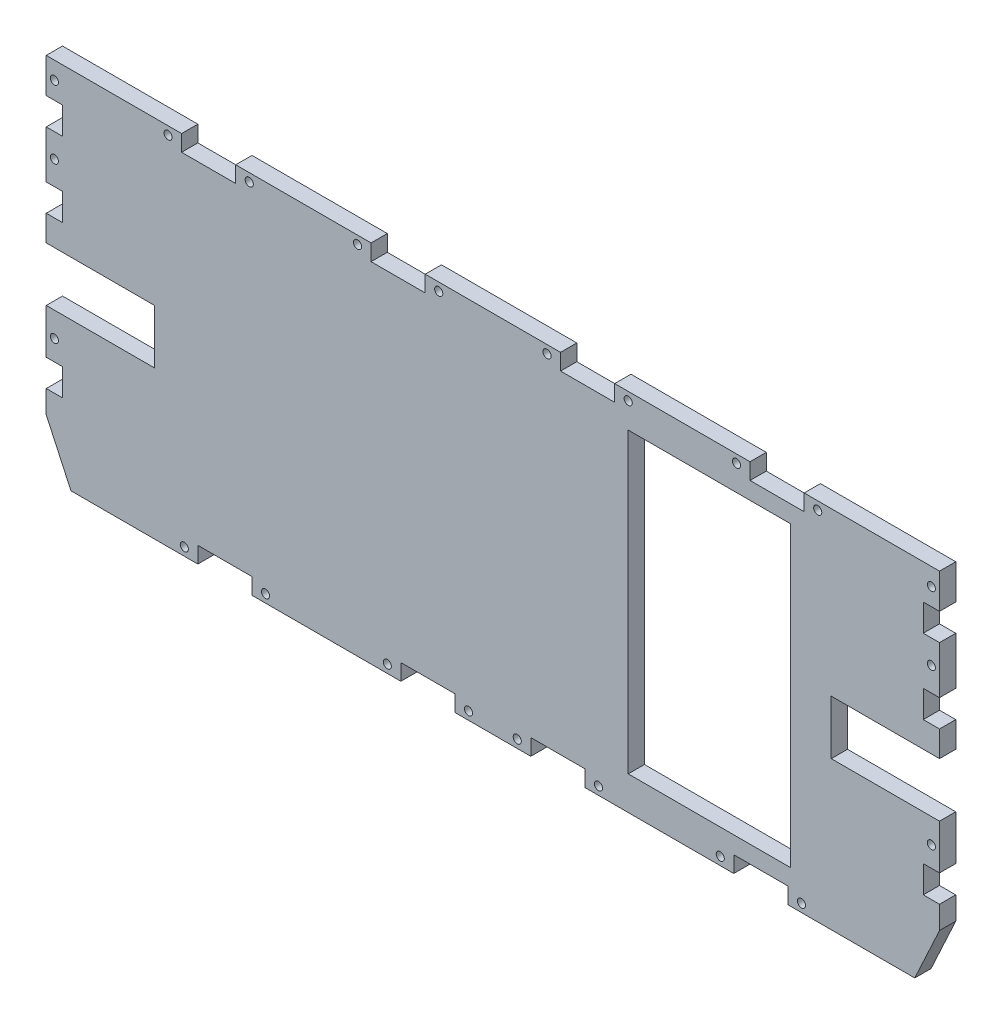
from build123d import *

# Parameters (mm, degrees)
BOSS_EXTRU_1_DEPTH      = 6
ESQUISSE3_W             = 6
ESQUISSE3_H             = 10
ESQUISSE3_W_2           = 20
ESQUISSE3_H_2           = 6
ESQUISSE3_W_3           = 60
ESQUISSE3_H_3           = 110
ESQUISSE3_W_4           = 40
ESQUISSE3_H_4           = 20
ENL_V_MAT_EXTRU_2_DEPTH = 6
ESQUISSE4_R             = 1.5
ENL_V_MAT_EXTRU_3_DEPTH = 6
ESQUISSE5_W             = 456.045253014
ESQUISSE5_H             = 136.228984631
ENL_V_MAT_EXTRU_4_DEPTH = 6


with BuildPart() as part:
    # Esquisse1 → Boss.-Extru.1 (new body)
    with BuildSketch(Plane.XY):
        Polygon((-165, 96.73), (165, 96.73), (165, -18.27), (123, -109.022410436), (-123, -109.022410436), (-165, -18.27), align=None)
    extrude(amount=BOSS_EXTRU_1_DEPTH)

    # Esquisse3 → Enlèv. mat.-Extru.2 (cut)
    with BuildSketch(Plane(origin=(0, 0, 0), x_dir=(-1, 0, 0), z_dir=(0, 0, -1))):
        with Locations((162, -4.85)):
            Rectangle(ESQUISSE3_W, ESQUISSE3_H)
        with Locations((162, 78.852589564)):
            Rectangle(ESQUISSE3_W, ESQUISSE3_H)
        with Locations((-24, -35.02)):
            Rectangle(ESQUISSE3_W_2, ESQUISSE3_H_2)
        with Locations((99, -35.02)):
            Rectangle(ESQUISSE3_W_2, ESQUISSE3_H_2)
        with Locations((-162, 51.23)):
            Rectangle(ESQUISSE3_W, ESQUISSE3_H)
        with Locations((-80, 29.355)):
            Rectangle(ESQUISSE3_W_3, ESQUISSE3_H_3)
        with Locations((24, -35.02)):
            Rectangle(ESQUISSE3_W_2, ESQUISSE3_H_2)
        with Locations((-162, 78.852589564)):
            Rectangle(ESQUISSE3_W, ESQUISSE3_H)
        with Locations((-162, -4.85)):
            Rectangle(ESQUISSE3_W, ESQUISSE3_H)
        with Locations((105, 93.73)):
            Rectangle(ESQUISSE3_W_2, ESQUISSE3_H_2)
        with Locations((-35, 93.73)):
            Rectangle(ESQUISSE3_W_2, ESQUISSE3_H_2)
        with Locations((35, 93.73)):
            Rectangle(ESQUISSE3_W_2, ESQUISSE3_H_2)
        with Locations((-105, 93.73)):
            Rectangle(ESQUISSE3_W_2, ESQUISSE3_H_2)
        with Locations((162, 51.23)):
            Rectangle(ESQUISSE3_W, ESQUISSE3_H)
        with Locations((-99, -35.02)):
            Rectangle(ESQUISSE3_W_2, ESQUISSE3_H_2)
        with Locations((-145, 26.73)):
            Rectangle(ESQUISSE3_W_4, ESQUISSE3_H_4)
        with Locations((145, 26.73)):
            Rectangle(ESQUISSE3_W_4, ESQUISSE3_H_4)
    extrude(amount=-ENL_V_MAT_EXTRU_2_DEPTH, mode=Mode.SUBTRACT)

    # Esquisse4 → Enlèv. mat.-Extru.3 (cut)
    with BuildSketch(Plane(origin=(0, 0, 0), x_dir=(-1, 0, 0), z_dir=(0, 0, -1))):
        with Locations((162, 7.65)):
            Circle(ESQUISSE4_R)
        with Locations((114, -35.02)):
            Circle(ESQUISSE4_R)
        with Locations((162, 65.042589564)):
            Circle(ESQUISSE4_R)
        with Locations((84, -35.02)):
            Circle(ESQUISSE4_R)
        with Locations((39, -35.02)):
            Circle(ESQUISSE4_R)
        with Locations((162, 90.29)):
            Circle(ESQUISSE4_R)
        with Locations((9, -35.02)):
            Circle(ESQUISSE4_R)
        with Locations((-9, -35.02)):
            Circle(ESQUISSE4_R)
        with Locations((-39, -35.02)):
            Circle(ESQUISSE4_R)
        with Locations((-84, -35.02)):
            Circle(ESQUISSE4_R)
        with Locations((120, 93.73)):
            Circle(ESQUISSE4_R)
        with Locations((-114, -35.02)):
            Circle(ESQUISSE4_R)
        with Locations((90, 93.73)):
            Circle(ESQUISSE4_R)
        with Locations((50, 93.73)):
            Circle(ESQUISSE4_R)
        with Locations((20, 93.73)):
            Circle(ESQUISSE4_R)
        with Locations((-20, 93.73)):
            Circle(ESQUISSE4_R)
        with Locations((-50, 93.73)):
            Circle(ESQUISSE4_R)
        with Locations((-90, 93.73)):
            Circle(ESQUISSE4_R)
        with Locations((-120, 93.73)):
            Circle(ESQUISSE4_R)
        with Locations((-162, 90.29)):
            Circle(ESQUISSE4_R)
        with Locations((-162, 65.042589564)):
            Circle(ESQUISSE4_R)
        with Locations((-162, 7.65)):
            Circle(ESQUISSE4_R)
    extrude(amount=-ENL_V_MAT_EXTRU_3_DEPTH, mode=Mode.SUBTRACT)

    # Esquisse5 → Enlèv. mat.-Extru.4 (cut)
    with BuildSketch(Plane(origin=(0, 0, 0), x_dir=(-1, 0, 0), z_dir=(0, 0, -1))):
        with Locations((-18.307092018, -106.134492316)):
            Rectangle(ESQUISSE5_W, ESQUISSE5_H)
    extrude(amount=-ENL_V_MAT_EXTRU_4_DEPTH, mode=Mode.SUBTRACT)


solid = part.part
